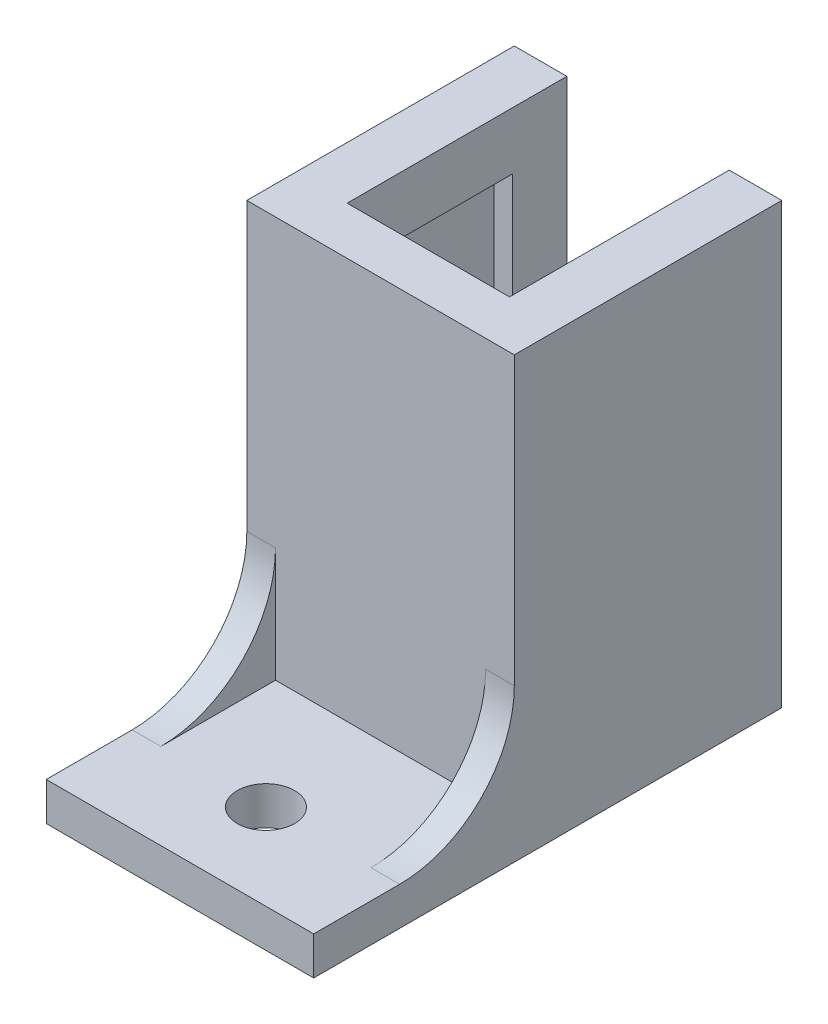
from build123d import *

# Parameters (mm, degrees)
SKETCH1_W           = 14
SKETCH1_H           = 23
BOSS_EXTRUDE1_DEPTH = 14
SKETCH2_W           = 10.4
SKETCH2_H           = 8.65
SKETCH2_W_2         = 8.5
SKETCH2_H_2         = 2.85
CUT_EXTRUDE1_DEPTH  = 20
SKETCH3_W           = 14
SKETCH3_H           = 10.5
SKETCH3_R           = 1.5
BOSS_EXTRUDE2_DEPTH = 2
BOSS_EXTRUDE3_DEPTH = 1.5
SKETCH5_W           = 8.5
SKETCH5_H           = 11.5
CUT_EXTRUDE2_DEPTH  = 4


with BuildPart() as part:
    # Sketch1 → Boss-Extrude1 (new body)
    with BuildSketch(Plane.XY):
        Rectangle(SKETCH1_W, SKETCH1_H)
    extrude(amount=BOSS_EXTRUDE1_DEPTH)

    # Sketch2 → Cut-Extrude1 (cut)
    with BuildSketch(Plane.XZ.offset(11.5)):
        with Locations((0, 7.175)):
            Rectangle(SKETCH2_W, SKETCH2_H)
        with Locations((0, 1.425)):
            Rectangle(SKETCH2_W_2, SKETCH2_H_2)
    extrude(amount=-CUT_EXTRUDE1_DEPTH, mode=Mode.SUBTRACT)

    # Sketch3 → Boss-Extrude2 (add)
    with BuildSketch(Plane.XZ.offset(11.5)):
        with Locations((0, 19.25)):
            Rectangle(SKETCH3_W, SKETCH3_H)
        with Locations((0, 20)):
            Circle(SKETCH3_R, mode=Mode.SUBTRACT)
    extrude(amount=-BOSS_EXTRUDE2_DEPTH)

    # Sketch4 → Boss-Extrude3 (add)
    with BuildSketch(Plane.ZY.offset(7)):
        with BuildLine():
            Line((14, -3.5), (14, -9.5))
            Line((14, -9.5), (20, -9.5))
            ThreePointArc((20, -9.5), (15.757359313, -7.742640687), (14, -3.5))
        make_face()
    boss_extrude3 = extrude(amount=-BOSS_EXTRUDE3_DEPTH)

    # Mirror1: Boss-Extrude3 across plane
    add(boss_extrude3.mirror(Plane(origin=(0, 0, 0), x_dir=(0, 0, 1), z_dir=(1, 0, 0))))

    # Sketch5 → Cut-Extrude2 (cut, through all)
    with BuildSketch(Plane.XZ.offset(-8.5)):
        with Locations((0, 5.75)):
            Rectangle(SKETCH5_W, SKETCH5_H)
    extrude(amount=-CUT_EXTRUDE2_DEPTH, mode=Mode.SUBTRACT)


solid = part.part
